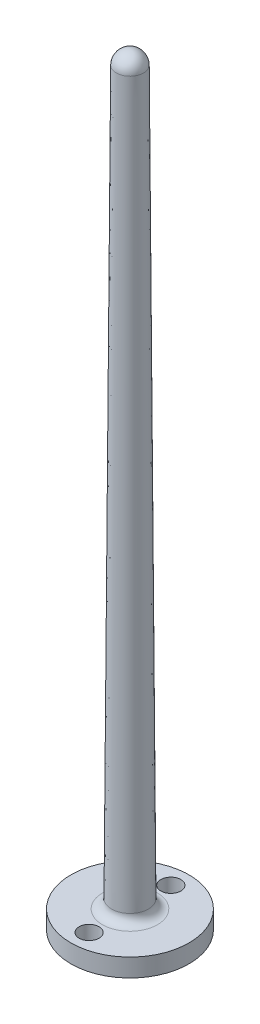
from build123d import *

# Parameters (mm, degrees)
SKETCH_1_R          = 6.5
EXTRUDE_1_DEPTH     = 2
SKETCH_2_R          = 1.1
CUT_EXTRUDE_1_DEPTH = 3


with BuildPart() as part:
    # 草图1 → 凸台-拉伸1 (new body)
    with BuildSketch(Plane(origin=(0, 0, 0), x_dir=(1, 0, 0), z_dir=(0, 1, 0))):
        Circle(SKETCH_1_R)
    extrude(amount=EXTRUDE_1_DEPTH)

    # 草图2 → 切除-拉伸1 (cut, through all)
    with BuildSketch(Plane(origin=(0, 2, 0), x_dir=(1, 0, 0), z_dir=(0, 1, 0))):
        with Locations((0, 4.5)):
            Circle(SKETCH_2_R)
        with Locations((0, -4.5)):
            Circle(SKETCH_2_R)
    extrude(amount=-CUT_EXTRUDE_1_DEPTH, mode=Mode.SUBTRACT)

    # 草图4 → 旋转1 (revolve)
    with BuildSketch(Plane.XY):
        with BuildLine():
            Line((1.50919925, 81.509373352), (2.02569692, 2.993421891))
            ThreePointArc((2.02569692, 2.993421891), (2.320898053, 2.290571318), (3.025675284, 2))
            Line((3.025675284, 2), (3, 2))
            Line((3, 2), (0, 2))
            Line((0, 2), (0, 83.938441204))
            ThreePointArc((0, 83.938441204), (1.05933326, 83.501690627), (1.503042796, 82.44525328))
            Line((1.503042796, 82.44525328), (1.50919925, 81.509373352))
        make_face()
    revolve(axis=Axis((0, 2, 0), (0, 1, 0)))


solid = part.part
